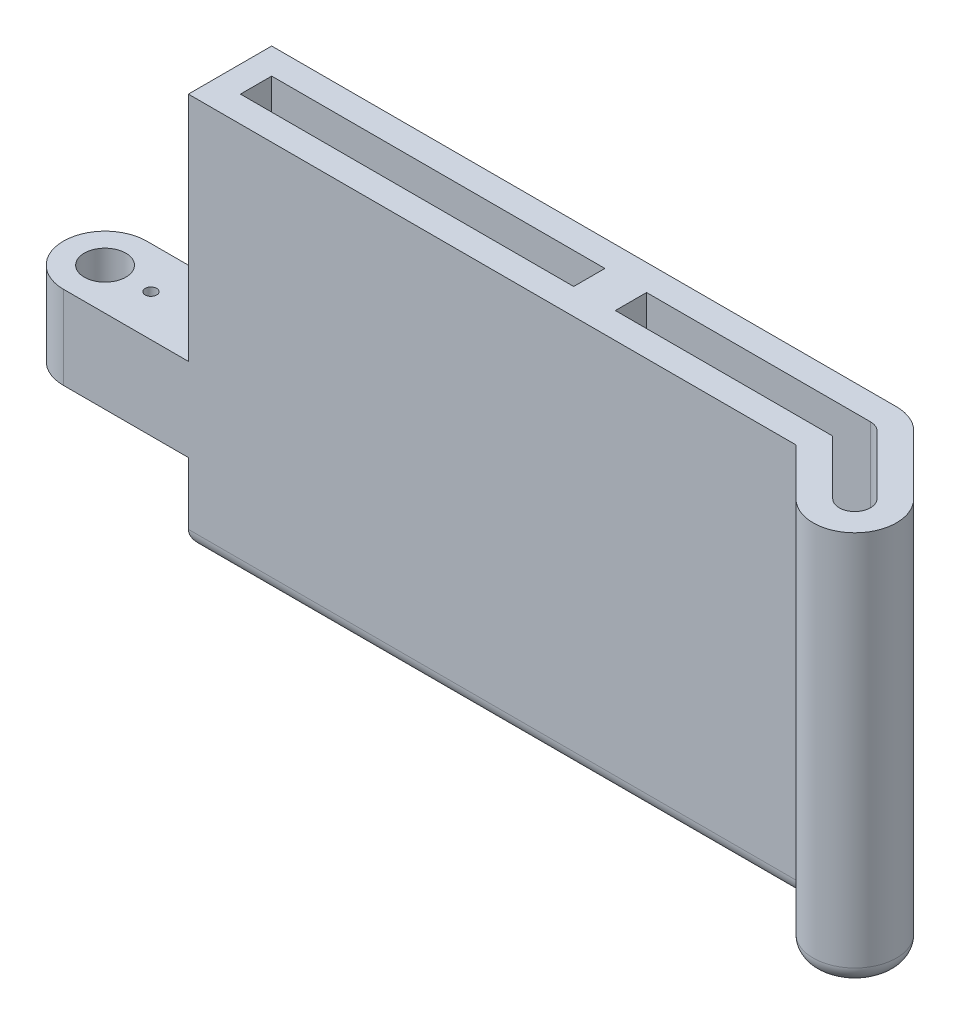
from build123d import *

# Parameters (mm, degrees)
BOSS_EXTRUDE1_DEPTH = 59.999999888
SKETCH2_W           = 25.4
SKETCH2_H           = 12.017000096
SKETCH2_H_2         = 35.282999792
CUT_EXTRUDE1_DEPTH  = 13.7
SKETCH3_R           = 0.877000024
CUT_EXTRUDE2_DEPTH  = 48.982999792
SKETCH4_R           = 3.175
CUT_EXTRUDE3_DEPTH  = 48.982999792
SKETCH5_W           = 50.8
SKETCH5_H           = 4.7625
CUT_EXTRUDE4_DEPTH  = 60.999999888
FILLET1_R           = 2.54


with BuildPart() as part:
    # Sketch1 → Boss-Extrude1 (new body)
    with BuildSketch(Plane(origin=(0, 0, 0), x_dir=(1, 0, 0), z_dir=(0, 1, 0))):
        with BuildLine():
            Line((0, 6.35), (114.3, 6.35))
            ThreePointArc((114.3, 6.35), (120.65, 0), (114.3, -6.35))
            Line((114.3, -6.35), (0, -6.35))
            ThreePointArc((0, -6.35), (-6.35, 0), (0, 6.35))
        make_face()
        with BuildLine():
            Line((118.790128061, 4.490128061), (127.770384182, -4.490128061))
            ThreePointArc((127.770384182, -4.490128061), (127.770384182, -13.470384182), (118.790128061, -13.470384182))
            Line((118.790128061, -13.470384182), (109.809871939, -4.490128061))
            ThreePointArc((109.809871939, -4.490128061), (109.809871939, 4.490128061), (118.790128061, 4.490128061))
        make_face()
    extrude(amount=BOSS_EXTRUDE1_DEPTH)

    # Sketch2 → Cut-Extrude1 (cut, through all)
    with BuildSketch(Plane.XY.offset(6.35)):
        with Locations((6.35, 6.008500048)):
            Rectangle(SKETCH2_W, SKETCH2_H)
        with Locations((6.35, 42.358499992)):
            Rectangle(SKETCH2_W, SKETCH2_H_2)
    extrude(amount=-CUT_EXTRUDE1_DEPTH, mode=Mode.SUBTRACT)

    # Sketch3 → Cut-Extrude2 (cut, through all)
    with BuildSketch(Plane.XZ.offset(-12.017000096)):
        with Locations((6.99999997, 0)):
            Circle(SKETCH3_R)
        with Locations((16.000000004, 0)):
            Circle(SKETCH3_R)
    extrude(amount=-CUT_EXTRUDE2_DEPTH, mode=Mode.SUBTRACT)

    # Sketch4 → Cut-Extrude3 (cut, through all)
    with BuildSketch(Plane.XZ.offset(-12.017000096)):
        Circle(SKETCH4_R)
    extrude(amount=-CUT_EXTRUDE3_DEPTH, mode=Mode.SUBTRACT)

    # Sketch5 → Cut-Extrude4 (cut, through all)
    with BuildSketch(Plane(origin=(0, 59.999999888, 0), x_dir=(1, 0, 0), z_dir=(0, 1, 0))):
        with Locations((48.41875, 0)):
            Rectangle(SKETCH5_W, SKETCH5_H)
        with BuildLine():
            Line((80.16875, 2.38125), (80.16875, -2.38125))
            Line((80.16875, -2.38125), (113.313653955, -2.38125))
            Line((113.313653955, -2.38125), (121.596458098, -10.664054144))
            ThreePointArc((121.596458098, -10.664054144), (124.964054144, -10.664054144), (124.964054144, -7.296458098))
            Line((124.964054144, -7.296458098), (115.983798023, 1.683798023))
            ThreePointArc((115.983798023, 1.683798023), (115.211264923, 2.199988137), (114.3, 2.38125))
            Line((114.3, 2.38125), (80.16875, 2.38125))
        make_face()
    extrude(amount=-CUT_EXTRUDE4_DEPTH, mode=Mode.SUBTRACT)

    # Fillet1
    fillet1_edges = [part.edges().sort_by_distance(p)[0] for p in [
        (116.730039796, 0, -5.866635031),
        (123.280256121, 0, 0),
        (65.359871939, 0, 6.35),
        (66.675, 0, -6.35),
        (19.05, 0, 0),
        (127.770384182, 0, 13.470384182),
        (115.22993597, 0, 9.910192091),
    ]]
    fillet(fillet1_edges, radius=FILLET1_R)


solid = part.part
